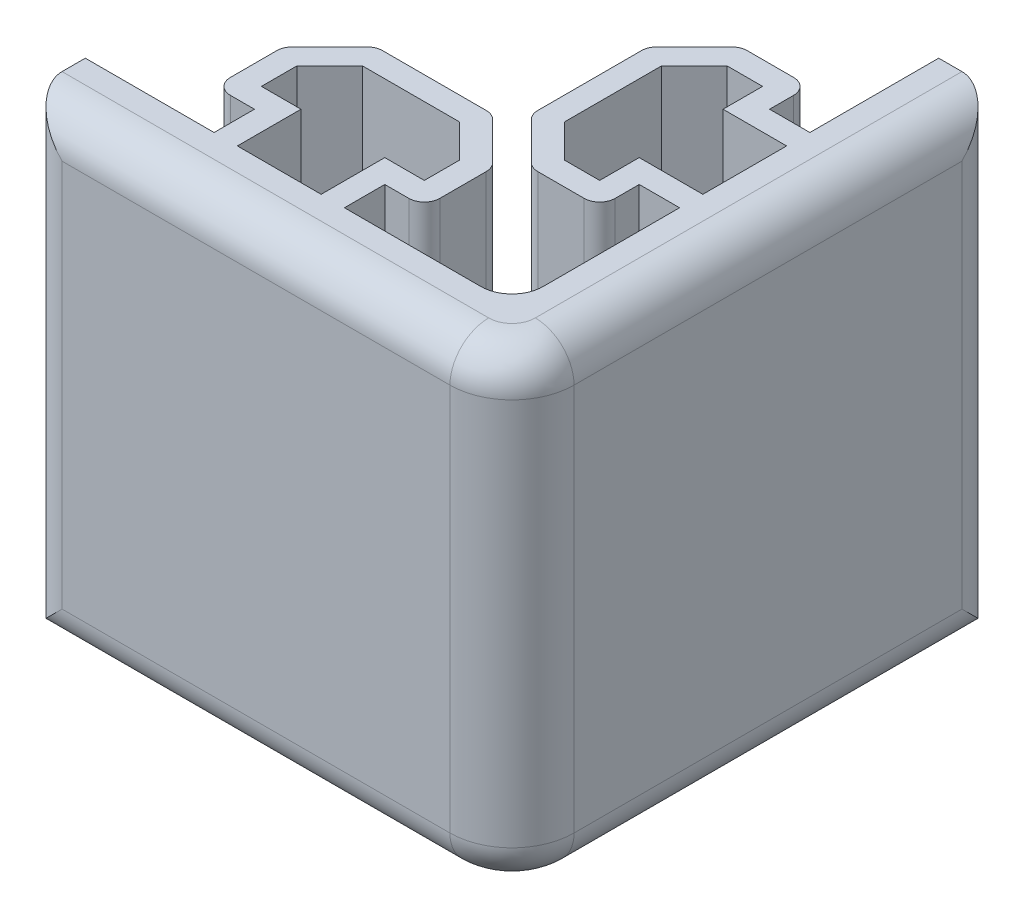
from build123d import *

# Parameters (mm, degrees)
BOSS_EXTRUDE1_DEPTH = 30
CUT_EXTRUDE3_REACH  = 51.163
SKETCH4_W           = 2.5
SKETCH4_H           = 30
CUT_EXTRUDE4_REACH  = 49.468
SKETCH5_W           = 2.5
SKETCH5_H           = 30
FILLET1_R           = 2.5
FILLET2_R           = 2
FILLET3_R           = 1
CUT_EXTRUDE5_REACH  = 42.274


with BuildPart() as part:
    # Sketch1 → Boss-Extrude1 (new body)
    with BuildSketch(Plane(origin=(0, 0, 0), x_dir=(1, 0, 0), z_dir=(0, 1, 0))):
        with BuildLine():
            Line((19, -15), (19, 15))
            Line((19, 15), (15, 15))
            Line((15, 15), (15, 4.2))
            Line((15, 4.2), (12.4, 4.2))
            Line((12.4, 4.2), (12.4, 6.75))
            Line((12.4, 6.75), (8, 6.75))
            Line((8, 6.75), (5, 3.75))
            Line((5, 3.75), (5, -3.75))
            Line((5, -3.75), (8, -6.75))
            Line((8, -6.75), (12.4, -6.75))
            Line((12.4, -6.75), (12.4, -4.2))
            Line((12.4, -4.2), (15, -4.2))
            Line((15, -4.2), (15, -15))
            Line((15, -15), (4.2, -15))
            Line((4.2, -15), (4.2, -12.4))
            Line((4.2, -12.4), (6.75, -12.4))
            Line((6.75, -12.4), (6.75, -8))
            Line((6.75, -8), (3.75, -5))
            Line((3.75, -5), (-3.75, -5))
            Line((-3.75, -5), (-6.75, -8))
            Line((-6.75, -8), (-6.75, -12.4))
            Line((-6.75, -12.4), (-4.2, -12.4))
            Line((-4.2, -12.4), (-4.2, -15))
            Line((-4.2, -15), (-15, -15))
            Line((-15, -15), (-15, -19))
            Line((-15, -19), (15, -19))
            ThreePointArc((15, -19), (17.828427125, -17.828427125), (19, -15))
        make_face()
    extrude(amount=BOSS_EXTRUDE1_DEPTH)

    # Sketch4 → Cut-Extrude3 (cut, up to next)
    with BuildSketch(Plane.XY.offset(19), mode=Mode.PRIVATE) as cut_extrude3_sk1:
        with Locations((-13.75, 15)):
            Rectangle(SKETCH4_W, SKETCH4_H)
    cut_extrude3_tool1 = extrude(cut_extrude3_sk1.sketch, amount=-CUT_EXTRUDE3_REACH, mode=Mode.PRIVATE) & part.part
    add(cut_extrude3_tool1.solids().sort_by_distance((-13.75, 15, 19))[0], mode=Mode.SUBTRACT)

    # Sketch5 → Cut-Extrude4 (cut, up to next)
    with BuildSketch(Plane(origin=(19, 0, 0), x_dir=(0, 0, -1), z_dir=(1, 0, 0)), mode=Mode.PRIVATE) as cut_extrude4_sk1:
        with Locations((13.75, 15)):
            Rectangle(SKETCH5_W, SKETCH5_H)
    cut_extrude4_tool1 = extrude(cut_extrude4_sk1.sketch, amount=-CUT_EXTRUDE4_REACH, mode=Mode.PRIVATE) & part.part
    add(cut_extrude4_tool1.solids().sort_by_distance((19, 15, -13.75))[0], mode=Mode.SUBTRACT)

    # Fillet1
    fillet1_edges = [part.edges().sort_by_distance(p)[0] for p in [
        (17.828427125, 30, 17.828427125),
        (19, 0, 1.25),
        (19, 30, 1.25),
        (19, 15, -12.5),
        (17.828427125, 0, 17.828427125),
        (1.25, 0, 19),
        (1.25, 30, 19),
        (-12.5, 15, 19),
    ]]
    fillet(fillet1_edges, radius=FILLET1_R)

    # Fillet2
    fillet2_edges = [part.edges().sort_by_distance(p)[0] for p in [
        (15, 15, 15),
    ]]
    fillet(fillet2_edges, radius=FILLET2_R)

    # Fillet3
    fillet3_edges = [part.edges().sort_by_distance(p)[0] for p in [
        (-6.75, 15, 12.4),
        (-6.75, 15, 8),
        (-3.75, 15, 5),
        (3.75, 15, 5),
        (6.75, 15, 8),
        (6.75, 15, 12.4),
        (12.4, 15, 6.75),
        (8, 15, 6.75),
        (5, 15, 3.75),
        (5, 15, -3.75),
        (8, 15, -6.75),
        (12.4, 15, -6.75),
    ]]
    fillet(fillet3_edges, radius=FILLET3_R)

    # Sketch6 → Cut-Extrude5 (cut, up to next)
    with BuildSketch(Plane(origin=(0, 30, 0), x_dir=(1, 0, 0), z_dir=(0, 1, 0)), mode=Mode.PRIVATE) as cut_extrude5_sk1:
        Polygon((5.25, -8.621320344), (3.128679656, -6.5), (-3.128679656, -6.5), (-5.25, -8.621320344), (-5.25, -10.9), (-2.7, -10.9), (-2.7, -15), (2.7, -15), (2.7, -10.9), (5.25, -10.9), align=None)
    cut_extrude5_tool1 = extrude(cut_extrude5_sk1.sketch, amount=-CUT_EXTRUDE5_REACH, mode=Mode.PRIVATE) & part.part
    # Sketch6 → Cut-Extrude5 (cut, up to next)
    with BuildSketch(Plane(origin=(0, 30, 0), x_dir=(1, 0, 0), z_dir=(0, 1, 0)), mode=Mode.PRIVATE) as cut_extrude5_sk2:
        Polygon((10.9, -2.7), (15, -2.7), (15, 2.7), (10.9, 2.7), (10.9, 5.25), (8.621320344, 5.25), (6.5, 3.128679656), (6.5, -3.128679656), (8.621320344, -5.25), (10.9, -5.25), align=None)
    cut_extrude5_tool2 = extrude(cut_extrude5_sk2.sketch, amount=-CUT_EXTRUDE5_REACH, mode=Mode.PRIVATE) & part.part
    add(cut_extrude5_tool1.solids().sort_by_distance((0, 30, 10.279151))[0], mode=Mode.SUBTRACT)
    add(cut_extrude5_tool2.solids().sort_by_distance((10.279151, 30, 0))[0], mode=Mode.SUBTRACT)


solid = part.part
